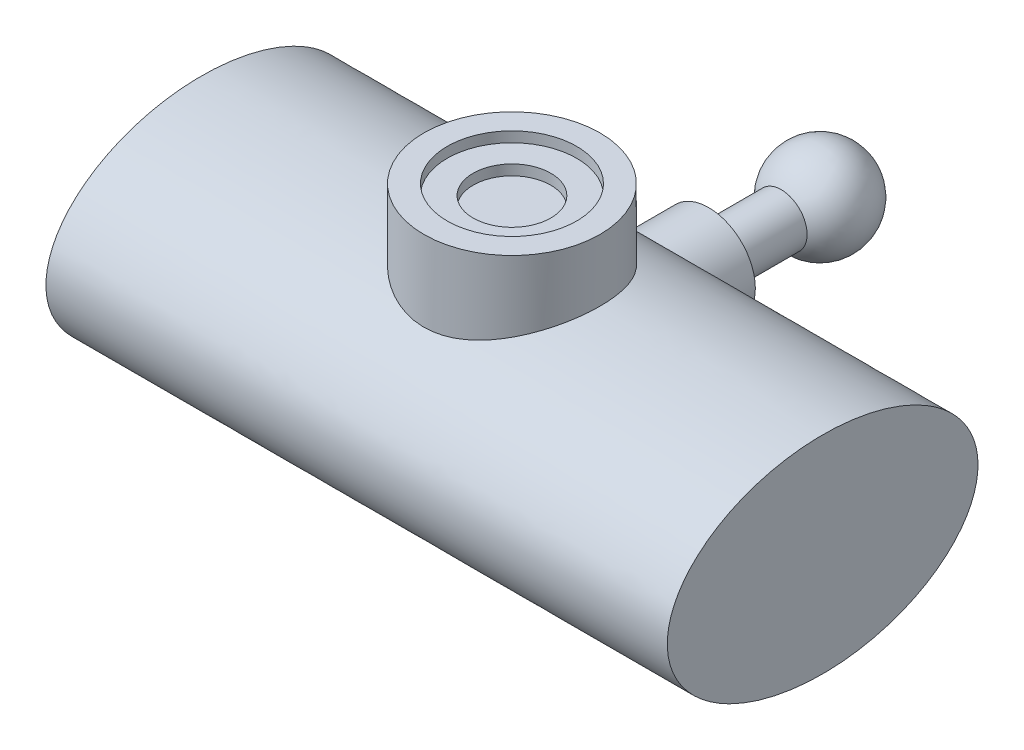
from build123d import *

# Parameters (mm, degrees)
SKETCH_1_R           = 2.5
EXTRUDE_1_DEPTH      = 7
SKETCH_2_R           = 4.5
EXTRUDE_2_DEPTH      = 10
SKETCH_3_RX          = 15
SKETCH_3_RY          = 10
EXTRUDE_3_DEPTH      = 30
EXTRUDE_3_DEPTH_BACK = 30
SKETCH_4_R           = 8.5
EXTRUDE_4_DEPTH      = 16
SKETCH_5_R           = 6.25
CUT_EXTRUDE_1_DEPTH  = 1
SKETCH_6_R           = 3.75
CUT_EXTRUDE_2_DEPTH  = 1


with BuildPart() as part:
    # Sketch 1 → Extrude 1 (new body)
    with BuildSketch(Plane.XY):
        Circle(SKETCH_1_R)
    extrude(amount=EXTRUDE_1_DEPTH)

    # Sketch 2 → Extrude 2 (add)
    with BuildSketch(Plane.XY.offset(7)):
        Circle(SKETCH_2_R)
    extrude(amount=EXTRUDE_2_DEPTH)

    # Sketch 3 → Extrude 3 (add, two sides)
    with BuildSketch(Plane(origin=(0, 0, 0), x_dir=(0, 0, -1), z_dir=(1, 0, 0))) as extrude_3_sk:
        with Locations((-26, 0)):
            Ellipse(SKETCH_3_RX, SKETCH_3_RY)
    extrude(amount=EXTRUDE_3_DEPTH)
    extrude(extrude_3_sk.sketch, amount=-EXTRUDE_3_DEPTH_BACK)

    # Sketch 4 → Extrude 4 (add)
    with BuildSketch(Plane(origin=(0, 0, 0), x_dir=(1, 0, 0), z_dir=(0, 1, 0))):
        with Locations((0, -26)):
            Circle(SKETCH_4_R)
    extrude(amount=EXTRUDE_4_DEPTH)

    # Sketch 5 → Cut-Extrude 1 (cut)
    with BuildSketch(Plane(origin=(0, 16, 0), x_dir=(1, 0, 0), z_dir=(0, 1, 0))):
        with Locations((0, -26)):
            Circle(SKETCH_5_R)
    extrude(amount=-CUT_EXTRUDE_1_DEPTH, mode=Mode.SUBTRACT)

    # Sketch 6 → Cut-Extrude 2 (cut)
    with BuildSketch(Plane(origin=(0, 15, 0), x_dir=(1, 0, 0), z_dir=(0, 1, 0))):
        with Locations((0, -26)):
            Circle(SKETCH_6_R)
    extrude(amount=-CUT_EXTRUDE_2_DEPTH, mode=Mode.SUBTRACT)

    # Sketch 7 → Revolve 3 (revolve)
    with BuildSketch(Plane(origin=(0, 0, 0), x_dir=(1, 0, 0), z_dir=(0, 1, 0))):
        with BuildLine():
            Line((0, -0.758342613), (0, 8.241657387))
            ThreePointArc((0, 8.241657387), (4.5, 3.741657387), (0, -0.758342613))
        make_face()
    revolve(axis=Axis((0, 0, -10.703740256), (0, 0, 1)))


solid = part.part
